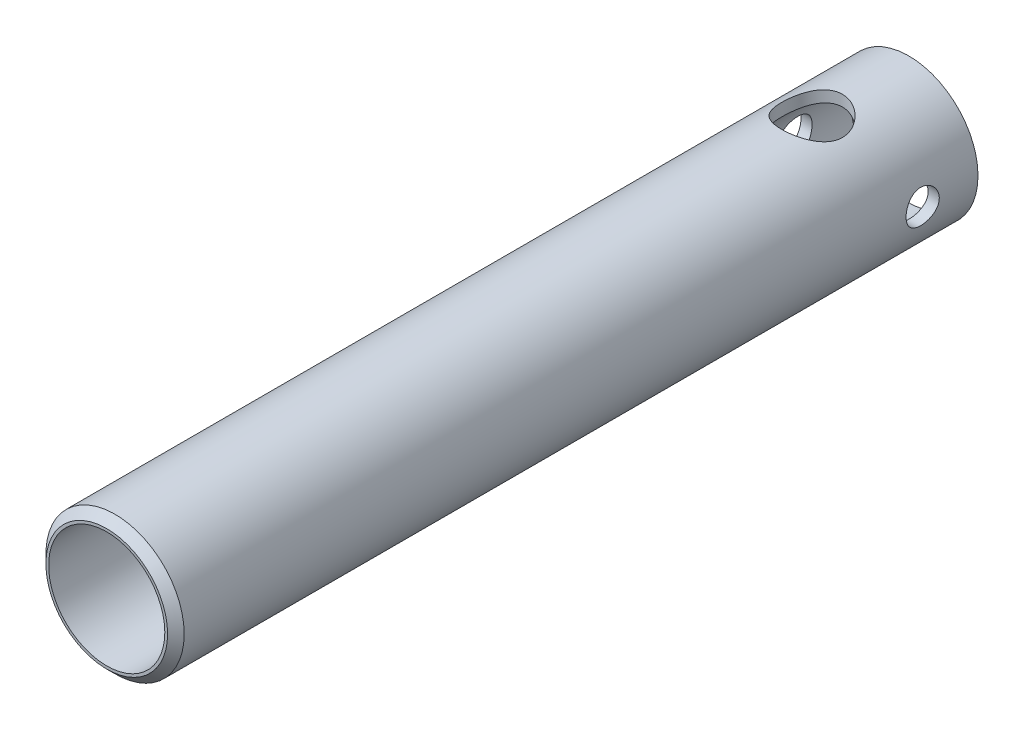
from build123d import *

# Parameters (mm, degrees)
SKETCH1_R               = 25
SKETCH1_R_2             = 21
BOSS_EXTRUDE1_DEPTH     = 145
CHAMFER1_SIZE           = 3
SKETCH2_R               = 11
CUT_EXTRUDE1_DEPTH      = 26
CUT_EXTRUDE1_DEPTH_BACK = 26
SKETCH3_R               = 6
CUT_EXTRUDE2_DEPTH      = 26.0000001
CUT_EXTRUDE2_DEPTH_BACK = 26.0000001
CUT_EXTRUDE3_REACH      = 27
SKETCH4_W               = 6
SKETCH4_H               = 75


with BuildPart() as part:
    # Sketch1 → Boss-Extrude1 (new body, symmetric)
    with BuildSketch(Plane.XY):
        Circle(SKETCH1_R)
        Circle(SKETCH1_R_2, mode=Mode.SUBTRACT)
    extrude(amount=BOSS_EXTRUDE1_DEPTH, both=True)

    # Chamfer1
    chamfer1_edges = [part.edges().sort_by_distance(p)[0] for p in [
        (-25, 0, 145),
    ]]
    chamfer(chamfer1_edges, length=CHAMFER1_SIZE)

    # Sketch2 → Cut-Extrude1 (cut, two sides)
    with BuildSketch(Plane(origin=(0, 0, 0), x_dir=(1, 0, 0), z_dir=(0, 1, 0))) as cut_extrude1_sk:
        with Locations((0, 110)):
            Circle(SKETCH2_R)
    extrude(amount=CUT_EXTRUDE1_DEPTH, mode=Mode.SUBTRACT)
    extrude(cut_extrude1_sk.sketch, amount=-CUT_EXTRUDE1_DEPTH_BACK, mode=Mode.SUBTRACT)

    # Sketch3 → Cut-Extrude2 (cut, two sides)
    with BuildSketch(Plane(origin=(0, 0, 0), x_dir=(0, 0, -1), z_dir=(1, 0, 0))) as cut_extrude2_sk:
        with Locations((125, 0)):
            Circle(SKETCH3_R)
    extrude(amount=CUT_EXTRUDE2_DEPTH, mode=Mode.SUBTRACT)
    extrude(cut_extrude2_sk.sketch, amount=-CUT_EXTRUDE2_DEPTH_BACK, mode=Mode.SUBTRACT)

    # Sketch4 → Cut-Extrude3 (cut, up to next)
    with BuildSketch(Plane(origin=(0, 0, 0), x_dir=(1, 0, 0), z_dir=(0, 1, 0)), mode=Mode.PRIVATE) as cut_extrude3_sk1:
        with Locations((0, -57.5)):
            Rectangle(SKETCH4_W, SKETCH4_H)
    cut_extrude3_tool1 = extrude(cut_extrude3_sk1.sketch, amount=-CUT_EXTRUDE3_REACH, mode=Mode.PRIVATE) & part.part
    add(cut_extrude3_tool1.solids().sort_by_distance((0, 0, 57.5))[0], mode=Mode.SUBTRACT)


solid = part.part
